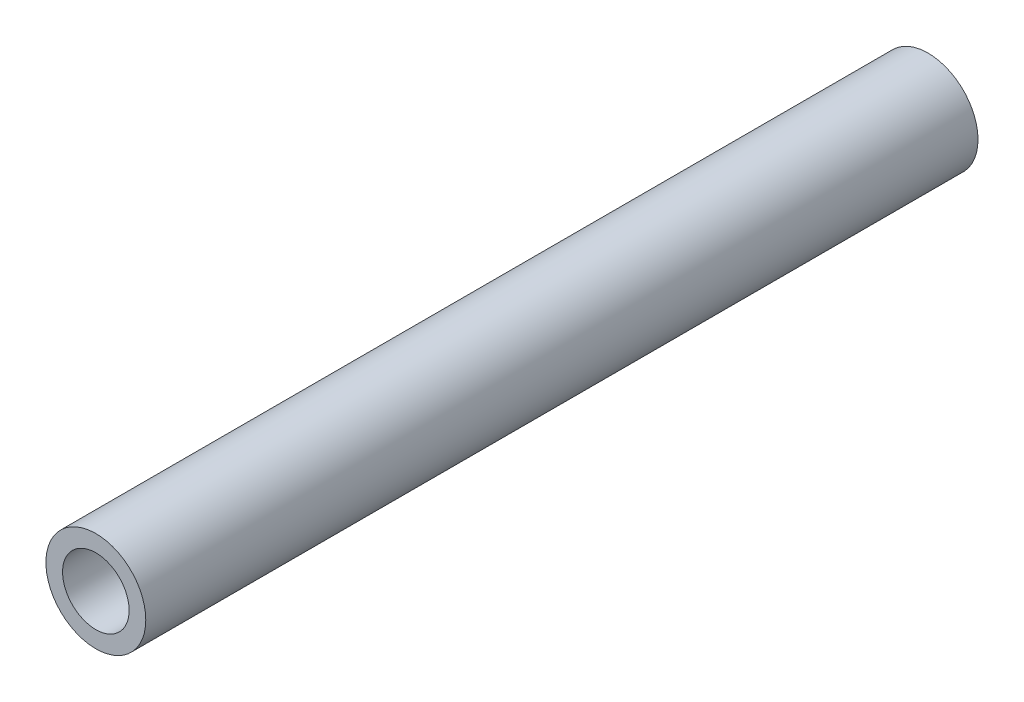
from build123d import *

# Parameters (mm, degrees)
SKETCH1_R           = 7.62
SKETCH1_R_2         = 5.08
BOSS_EXTRUDE1_DEPTH = 127


with BuildPart() as part:
    # Sketch1 → Boss-Extrude1 (new body)
    with BuildSketch(Plane.XY):
        Circle(SKETCH1_R)
        Circle(SKETCH1_R_2, mode=Mode.SUBTRACT)
    extrude(amount=BOSS_EXTRUDE1_DEPTH)


solid = part.part
